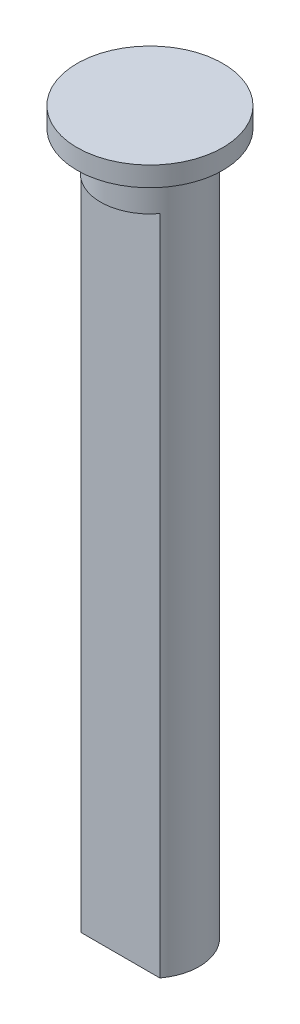
from build123d import *

# Parameters (mm, degrees)
EXTRUDE_1_DEPTH = 27.8
SKETCH_2_R      = 2.5
EXTRUDE_2_DEPTH = 2
SKETCH_3_R      = 3.7
EXTRUDE_3_DEPTH = 1
EXTRUDE_4_DEPTH = 2
EXTRUDE_5_DEPTH = 3.8


with BuildPart() as part:
    # 草图1 → 凸台-拉伸1 (new body)
    with BuildSketch(Plane(origin=(0, 0, 0), x_dir=(1, 0, 0), z_dir=(0, 1, 0))):
        with BuildLine():
            Line((-2, -1.5), (2, -1.5))
            ThreePointArc((2, -1.5), (0, 2.5), (-2, -1.5))
        make_face()
    extrude(amount=EXTRUDE_1_DEPTH)

    # 草图2 → 凸台-拉伸2 (add)
    with BuildSketch(Plane(origin=(0, 27.8, 0), x_dir=(1, 0, 0), z_dir=(0, 1, 0))):
        Circle(SKETCH_2_R)
    extrude(amount=EXTRUDE_2_DEPTH)

    # 草图3 → 凸台-拉伸3 (add)
    with BuildSketch(Plane(origin=(0, 29.8, 0), x_dir=(1, 0, 0), z_dir=(0, 1, 0))):
        Circle(SKETCH_3_R)
    extrude(amount=EXTRUDE_3_DEPTH)

    # 草图4 → 凸台-拉伸4 (add)
    with BuildSketch(Plane.XZ):
        with BuildLine():
            Line((-2, 1.5), (2, 1.5))
            ThreePointArc((2, 1.5), (0, -2.5), (-2, 1.5))
        make_face()
    extrude(amount=EXTRUDE_4_DEPTH)

    # 草图5 → 凸台-拉伸5 (add)
    with BuildSketch(Plane.XZ.offset(2)):
        with BuildLine():
            Line((-2, 1.5), (2, 1.5))
            ThreePointArc((2, 1.5), (0, -2.5), (-2, 1.5))
        make_face()
    extrude(amount=EXTRUDE_5_DEPTH)


solid = part.part
